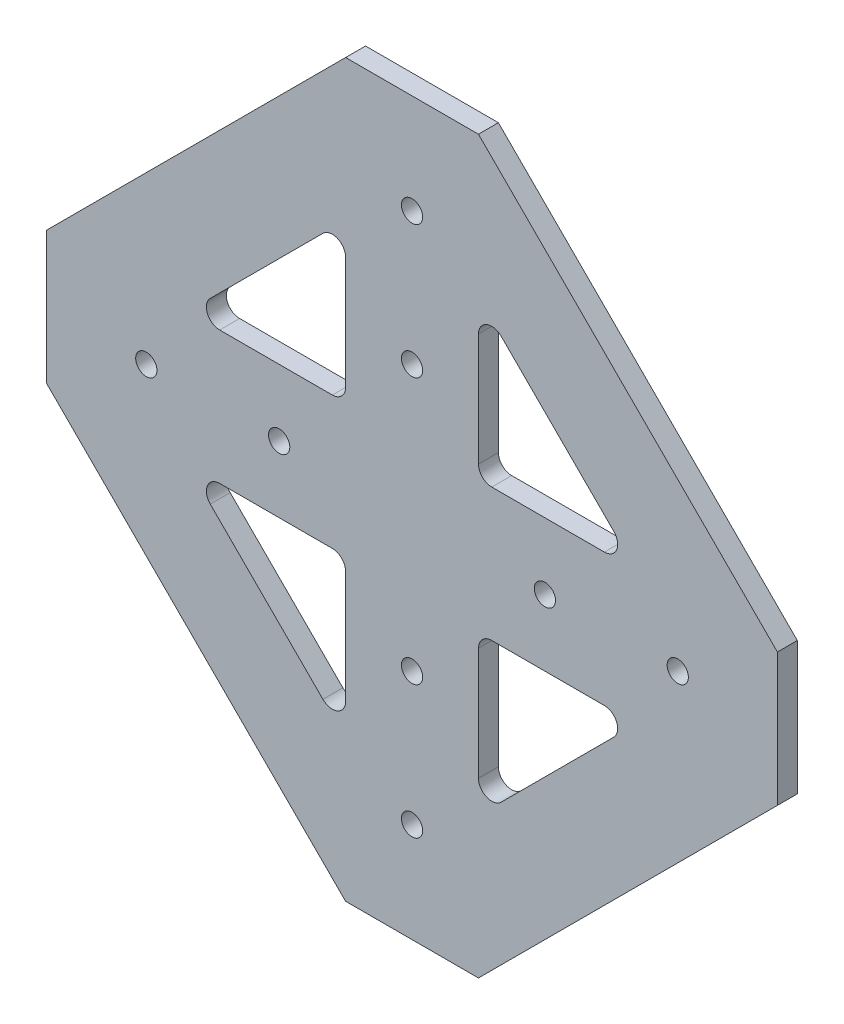
from build123d import *

# Parameters (mm, degrees)
EXTRUDE1_DEPTH     = 3
SKETCH2_R          = 1.6
CUT_EXTRUDE1_DEPTH = 3
EXTRUDE2_DEPTH     = 10


with BuildPart() as part:
    # Sketch1 → Extrude1 (new body)
    with BuildSketch(Plane.XY):
        Polygon((-253.489921235, 347.497048214), (-233.489921235, 347.497048214), (-188.489921235, 302.497048214), (-188.489921235, 282.497048214), (-233.489921235, 237.497048214), (-253.489921235, 237.497048214), (-298.489921235, 282.497048214), (-298.489921235, 302.497048214), align=None)
    extrude(amount=EXTRUDE1_DEPTH)

    # Sketch2 → Cut-Extrude1 (cut)
    with BuildSketch(Plane.XY.offset(3)):
        with Locations((-203.489921235, 292.497048214)):
            Circle(SKETCH2_R)
        with Locations((-223.489921235, 292.497048214)):
            Circle(SKETCH2_R)
        with Locations((-243.489921235, 252.497048214)):
            Circle(SKETCH2_R)
        with Locations((-243.489921235, 272.497048214)):
            Circle(SKETCH2_R)
        with Locations((-283.489921235, 292.497048214)):
            Circle(SKETCH2_R)
        with Locations((-263.489921235, 292.497048214)):
            Circle(SKETCH2_R)
        with Locations((-243.489921235, 312.497048214)):
            Circle(SKETCH2_R)
        with Locations((-243.489921235, 332.497048214)):
            Circle(SKETCH2_R)
    extrude(amount=-CUT_EXTRUDE1_DEPTH, mode=Mode.SUBTRACT)

    # Sketch3 → Extrude2 (cut)
    with BuildSketch(Plane.XY.offset(3)):
        with BuildLine():
            Line((-256.904134797, 322.869631216), (-273.862504237, 305.911261776))
            ThreePointArc((-273.862504237, 305.911261776), (-274.29604974, 303.731681349), (-272.448290675, 302.497048214))
            Line((-272.448290675, 302.497048214), (-255.489921235, 302.497048214))
            ThreePointArc((-255.489921235, 302.497048214), (-254.075707673, 303.082834651), (-253.489921235, 304.497048214))
            Line((-253.489921235, 304.497048214), (-253.489921235, 321.455417653))
            ThreePointArc((-253.489921235, 321.455417653), (-254.72455437, 323.303176718), (-256.904134797, 322.869631216))
        make_face()
        with BuildLine():
            Line((-233.489921235, 304.497048214), (-233.489921235, 321.455417653))
            ThreePointArc((-233.489921235, 321.455417653), (-232.2552881, 323.303176718), (-230.075707673, 322.869631216))
            Line((-230.075707673, 322.869631216), (-213.117338233, 305.911261776))
            ThreePointArc((-213.117338233, 305.911261776), (-212.68379273, 303.731681349), (-214.531551795, 302.497048214))
            Line((-214.531551795, 302.497048214), (-231.489921235, 302.497048214))
            ThreePointArc((-231.489921235, 302.497048214), (-232.904134797, 303.082834651), (-233.489921235, 304.497048214))
        make_face()
        with BuildLine():
            Line((-230.075707673, 262.124465212), (-213.117338233, 279.082834651))
            ThreePointArc((-213.117338233, 279.082834651), (-212.68379273, 281.262415078), (-214.531551795, 282.497048214))
            Line((-214.531551795, 282.497048214), (-231.489921235, 282.497048214))
            ThreePointArc((-231.489921235, 282.497048214), (-232.904134797, 281.911261776), (-233.489921235, 280.497048214))
            Line((-233.489921235, 280.497048214), (-233.489921235, 263.538678774))
            ThreePointArc((-233.489921235, 263.538678774), (-232.2552881, 261.690919709), (-230.075707673, 262.124465212))
        make_face()
        with BuildLine():
            Line((-253.489921235, 280.497048214), (-253.489921235, 263.538678774))
            ThreePointArc((-253.489921235, 263.538678774), (-254.72455437, 261.690919709), (-256.904134797, 262.124465212))
            Line((-256.904134797, 262.124465212), (-273.862504237, 279.082834651))
            ThreePointArc((-273.862504237, 279.082834651), (-274.29604974, 281.262415078), (-272.448290675, 282.497048214))
            Line((-272.448290675, 282.497048214), (-255.489921235, 282.497048214))
            ThreePointArc((-255.489921235, 282.497048214), (-254.075707673, 281.911261776), (-253.489921235, 280.497048214))
        make_face()
    extrude(amount=-EXTRUDE2_DEPTH, mode=Mode.SUBTRACT)


solid = part.part
